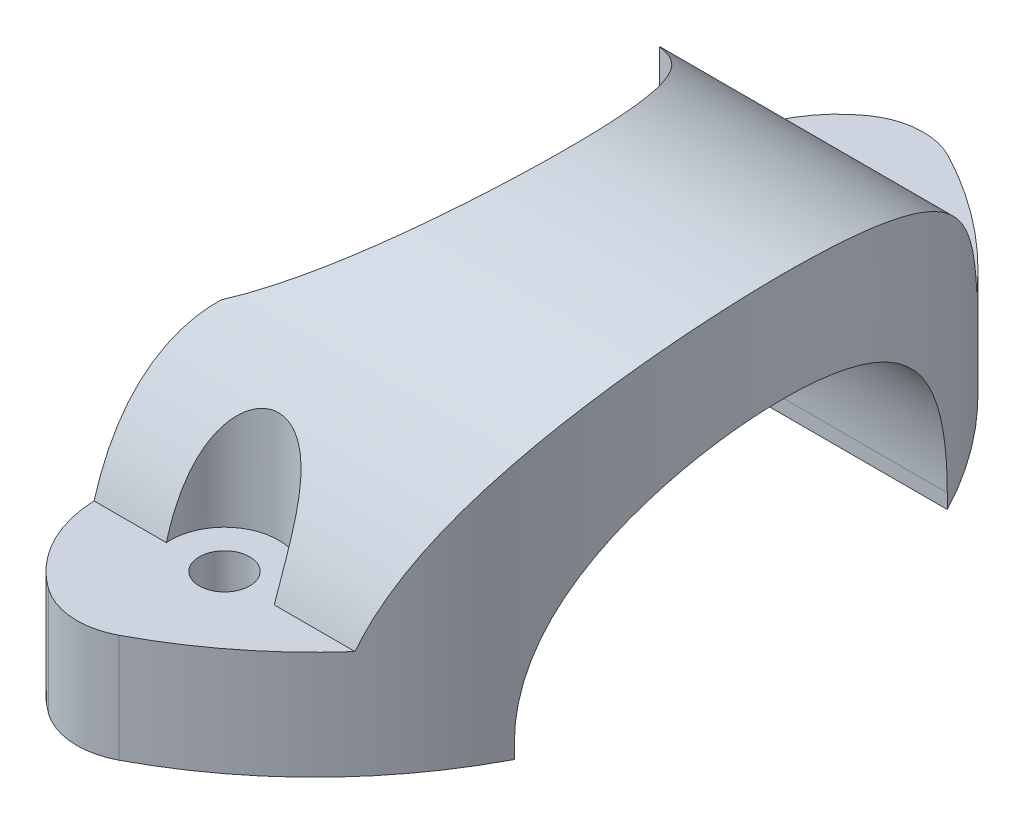
from build123d import *

# Parameters (mm, degrees)
SKETCH1_R               = 4.7625
SKETCH1_R_2             = 4.445
BOSS_EXTRUDE1_DEPTH     = 76.2
CUT_EXTRUDE6_DEPTH      = 61.487180317
CUT_EXTRUDE7_DEPTH      = 7.187819683
CUT_EXTRUDE7_DEPTH_BACK = 61.487180417
SKETCH10_R              = 9.525
CUT_EXTRUDE8_DEPTH      = 41.6400001


with BuildPart() as part:
    # Sketch1 → Boss-Extrude1 (new body)
    with BuildSketch(Plane(origin=(0, 0, 0), x_dir=(1, 0, 0), z_dir=(0, 1, 0))):
        with BuildLine():
            ThreePointArc((38.550556967, -72.995596152), (82.55, 0), (38.550556967, 72.995596152))
            ThreePointArc((38.550556967, 72.995596152), (31.812827991, 74.439846796), (25.312638114, 72.152843684))
            ThreePointArc((25.312638114, 72.152843684), (15.978447625, 56.116855626), (22.062819683, 38.588009636))
            ThreePointArc((22.062819683, 38.588009636), (44.45, 0), (22.062819683, -38.588009636))
            ThreePointArc((22.062819683, -38.588009636), (15.978447625, -56.116855626), (25.312638114, -72.152843684))
            ThreePointArc((25.312638114, -72.152843684), (31.812827991, -74.439846796), (38.550556967, -72.995596152))
        make_face()
        with Locations((38.1, 53.975)):
            Circle(SKETCH1_R, mode=Mode.SUBTRACT)
        with Locations((38.1, -53.975)):
            Circle(SKETCH1_R_2, mode=Mode.SUBTRACT)
    extrude(amount=BOSS_EXTRUDE1_DEPTH)

    # Sketch7 → Cut-Extrude6 (cut, through all)
    with BuildSketch(Plane.ZY.offset(-22.062819683)):
        with BuildLine():
            Line((-38.1, 2.54), (-38.1, 0))
            Line((-38.1, 0), (38.1, 0))
            Line((38.1, 0), (38.1, 2.54))
            ThreePointArc((38.1, 2.54), (0, 40.64), (-38.1, 2.54))
        make_face()
    extrude(amount=-CUT_EXTRUDE6_DEPTH, mode=Mode.SUBTRACT)

    # Sketch9 → Cut-Extrude7 (cut, two sides)
    with BuildSketch(Plane.ZY.offset(-22.062819683)) as cut_extrude7_sk:
        with BuildLine():
            Line((-74.465504436, 76.2), (-74.465504436, 19.05))
            Line((-74.465504436, 19.05), (-54.71327444, 19.05))
            ThreePointArc((-54.71327444, 19.05), (0, 59.69), (54.71327444, 19.05))
            Line((54.71327444, 19.05), (74.465504436, 19.05))
            Line((74.465504436, 19.05), (74.465504436, 76.2))
            Line((74.465504436, 76.2), (-74.465504436, 76.2))
        make_face()
    extrude(amount=CUT_EXTRUDE7_DEPTH, mode=Mode.SUBTRACT)
    extrude(cut_extrude7_sk.sketch, amount=-CUT_EXTRUDE7_DEPTH_BACK, mode=Mode.SUBTRACT)

    # Sketch10 → Cut-Extrude8 (cut, through all)
    with BuildSketch(Plane(origin=(0, 19.05, 0), x_dir=(1, 0, 0), z_dir=(0, 1, 0))):
        with Locations((38.1, 53.975)):
            Circle(SKETCH10_R)
        with Locations((38.1, -53.975)):
            Circle(SKETCH10_R)
    extrude(amount=CUT_EXTRUDE8_DEPTH, mode=Mode.SUBTRACT)


solid = part.part
